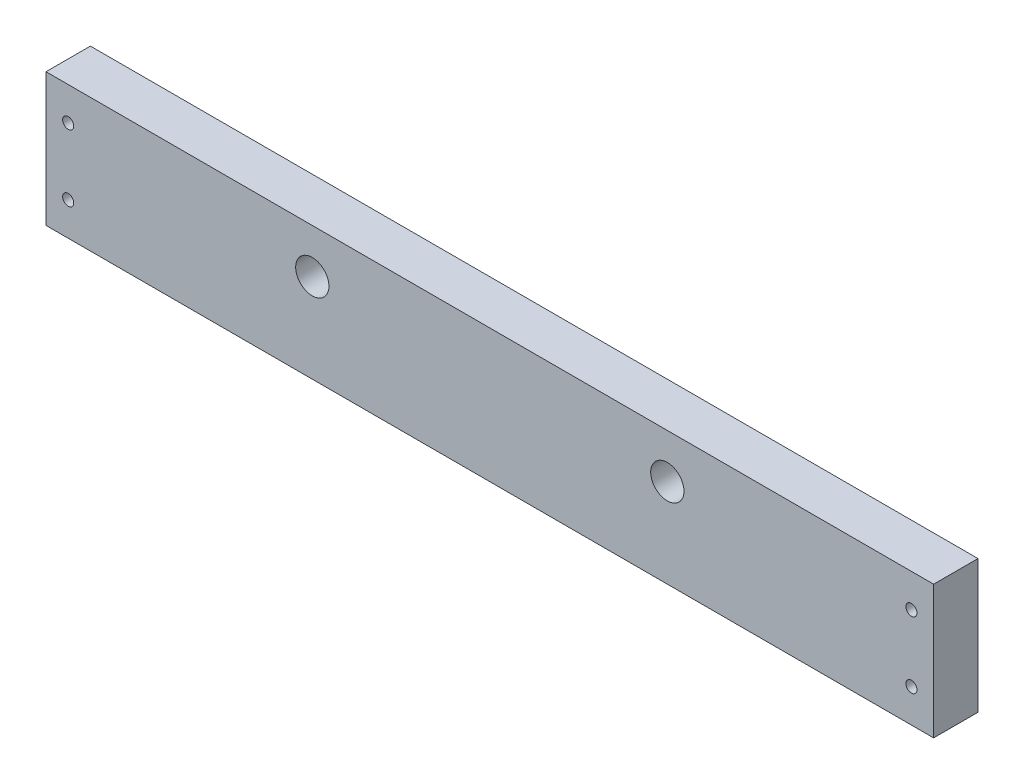
from build123d import *

# Parameters (mm, degrees)
SKETCH1_W           = 254
SKETCH1_H           = 38.1
SKETCH1_R           = 4.7625
SKETCH1_R_2         = 1.5875
BOSS_EXTRUDE1_DEPTH = 12.7


with BuildPart() as part:
    # Sketch1 → Boss-Extrude1 (new body)
    with BuildSketch(Plane.XY):
        with Locations((0, -6.35)):
            Rectangle(SKETCH1_W, SKETCH1_H)
        with Locations((-50.8, 0)):
            Circle(SKETCH1_R, mode=Mode.SUBTRACT)
        with Locations((50.8, 0)):
            Circle(SKETCH1_R, mode=Mode.SUBTRACT)
        with Locations((-120.65, 3.175)):
            Circle(SKETCH1_R_2, mode=Mode.SUBTRACT)
        with Locations((-120.65, -15.875)):
            Circle(SKETCH1_R_2, mode=Mode.SUBTRACT)
        with Locations((120.65, 3.175)):
            Circle(SKETCH1_R_2, mode=Mode.SUBTRACT)
        with Locations((120.65, -15.875)):
            Circle(SKETCH1_R_2, mode=Mode.SUBTRACT)
    extrude(amount=BOSS_EXTRUDE1_DEPTH)


solid = part.part
